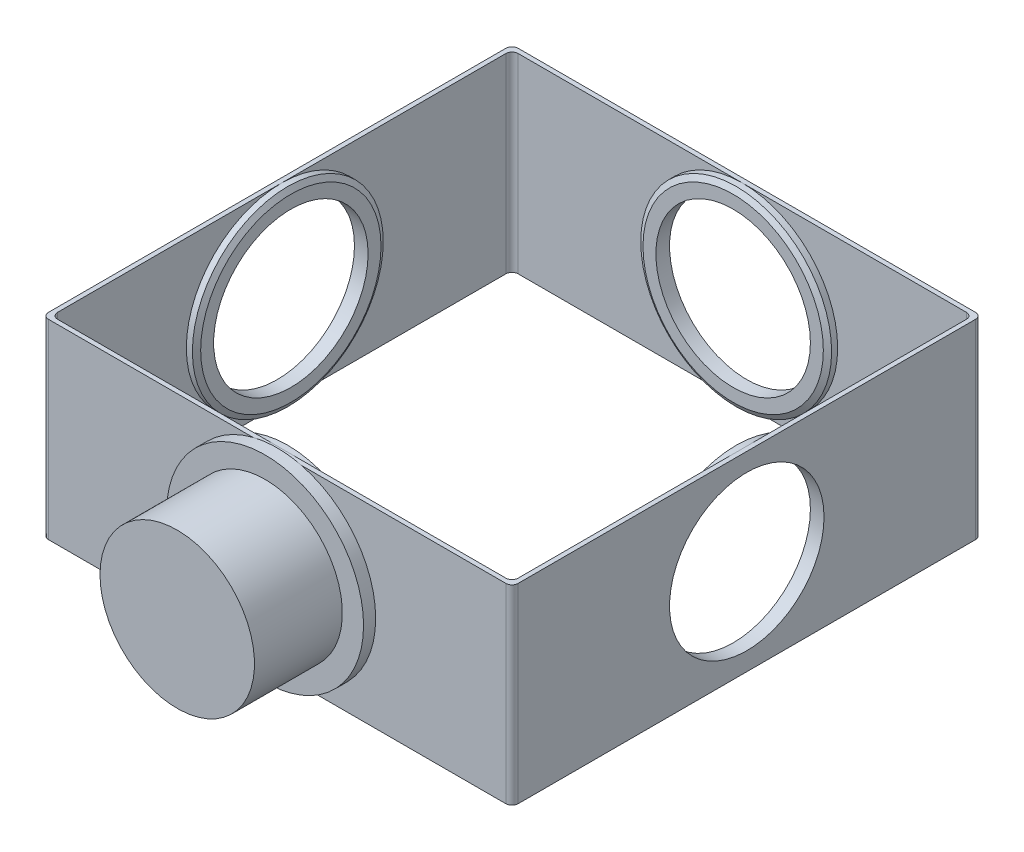
from build123d import *
from OCP.BRepFilletAPI import BRepFilletAPI_MakeChamfer

# Parameters (mm, degrees)
EXTRUDE_1_DEPTH     = 63
CUT_EXTRUDE_1_REACH = 230.077
SKETCH_2_R          = 25.5
CUT_EXTRUDE_2_REACH = 230.077
SKETCH_3_R          = 25.5
SKETCH_4_R          = 31.5
SKETCH_4_R_2        = 25.5
EXTRUDE_1_2_DEPTH   = 3
CHAMFER_1_SIZE      = 1
CHAMFER_1_SIZE2     = 1.732050808
SKETCH_5_R          = 31.5
SKETCH_5_R_2        = 25.5
EXTRUDE_4_DEPTH     = 3
CHAMFER_2_SIZE      = 1
CHAMFER_2_SIZE2     = 1.732050808
SKETCH_7_R          = 31.5
SKETCH_7_R_2        = 25.5
EXTRUDE_5_DEPTH     = 3
SKETCH_8_R          = 31.5
SKETCH_8_R_2        = 25.5
EXTRUDE_6_DEPTH     = 3
CHAMFER_3_SIZE      = 1
CHAMFER_3_SIZE2     = 1.732050808
SKETCH_9_R          = 32.5
EXTRUDE_7_DEPTH     = 4
SKETCH_10_R         = 25.5
EXTRUDE_8_DEPTH     = 29


with BuildPart() as part:
    # Эскиз1 → Extrude 1 (new body)
    with BuildSketch(Plane(origin=(0, 0, 0), x_dir=(1, 0, 0), z_dir=(0, 1, 0))):
        with BuildLine():
            Line((2, 0), (153, 0))
            ThreePointArc((153, 0), (154.414213562, 0.585786438), (155, 2))
            Line((155, 2), (155, 153))
            ThreePointArc((155, 153), (154.414213562, 154.414213562), (153, 155))
            Line((153, 155), (2, 155))
            ThreePointArc((2, 155), (0.585786438, 154.414213562), (0, 153))
            Line((0, 153), (0, 2))
            ThreePointArc((0, 2), (0.585786438, 0.585786438), (2, 0))
        make_face()
        with BuildLine():
            Line((3.5, 153.5), (151.5, 153.5))
            ThreePointArc((151.5, 153.5), (152.914213562, 152.914213562), (153.5, 151.5))
            Line((153.5, 151.5), (153.5, 3.5))
            ThreePointArc((153.5, 3.5), (152.914213562, 2.085786438), (151.5, 1.5))
            Line((151.5, 1.5), (3.5, 1.5))
            ThreePointArc((3.5, 1.5), (2.085786438, 2.085786438), (1.5, 3.5))
            Line((1.5, 3.5), (1.5, 151.5))
            ThreePointArc((1.5, 151.5), (2.085786438, 152.914213562), (3.5, 153.5))
        make_face(mode=Mode.SUBTRACT)
    extrude(amount=EXTRUDE_1_DEPTH)

    # Вырез-Вытянуть1: up to this face of the body (flat: up to its plane)
    cut_extrude_1_end = Plane(part.part.faces().sort_by_distance((77.5, 31.5, -155))[0])
    # Эскиз2 → Вырез-Вытянуть1 (cut, up to the picked face)
    with BuildSketch(Plane.XY, mode=Mode.PRIVATE) as cut_extrude_1_sk1:
        with Locations((77.5, 31.5)):
            Circle(SKETCH_2_R)
    cut_extrude_1_tool1 = split(extrude(cut_extrude_1_sk1.sketch, amount=-CUT_EXTRUDE_1_REACH, mode=Mode.PRIVATE), bisect_by=cut_extrude_1_end, keep=Keep.BOTH, mode=Mode.PRIVATE)
    add(cut_extrude_1_tool1.solids().sort_by(Axis((77.5, 31.5, 0), (0, 0, -1)))[0], mode=Mode.SUBTRACT)

    # Вырез-Вытянуть2: up to this face of the body (flat: up to its plane)
    cut_extrude_2_end = Plane(part.part.faces().sort_by_distance((0, 31.5, -77.5))[0])
    # Эскиз3 → Вырез-Вытянуть2 (cut, up to the picked face)
    with BuildSketch(Plane(origin=(155, 0, 0), x_dir=(0, 0, -1), z_dir=(1, 0, 0)), mode=Mode.PRIVATE) as cut_extrude_2_sk1:
        with Locations((77.5, 31.5)):
            Circle(SKETCH_3_R)
    cut_extrude_2_tool1 = split(extrude(cut_extrude_2_sk1.sketch, amount=-CUT_EXTRUDE_2_REACH, mode=Mode.PRIVATE), bisect_by=cut_extrude_2_end, keep=Keep.BOTH, mode=Mode.PRIVATE)
    add(cut_extrude_2_tool1.solids().sort_by(Axis((155, 31.5, -77.5), (-1, 0, 0)))[0], mode=Mode.SUBTRACT)

    # Эскиз4 → Extrude 1 2 (add)
    with BuildSketch(Plane(origin=(0, 0, -1.5), x_dir=(-1, 0, 0), z_dir=(0, 0, -1))):
        with Locations(Location((-77.5, 31.5, 0), (0, 0, 270))):
            Circle(SKETCH_4_R)
        with Locations(Location((-77.5, 31.5, 0), (0, 0, 180))):
            Circle(SKETCH_4_R_2, mode=Mode.SUBTRACT)
    extrude(amount=EXTRUDE_1_2_DEPTH)

    # Фаска1 шайба
    chamfer_1_edges = [part.edges().sort_by_distance(p)[0] for p in [
        (77.5, 63, -4.5),
    ]]
    chamfer_1_side = [part.faces().sort_by_distance(p)[0] for p in [
        (77.5, 63, -3),
    ]]
    chamfer(chamfer_1_edges, length=CHAMFER_1_SIZE, length2=CHAMFER_1_SIZE2, reference=chamfer_1_side[0])

    # Эскиз5 → Бобышка-Вытянуть4 (add)
    with BuildSketch(Plane(origin=(1.5, 0, 0), x_dir=(0, 0, -1), z_dir=(1, 0, 0))):
        with Locations(Location((77.5, 31.5, 0), (0, 0, 270))):
            Circle(SKETCH_5_R)
        with Locations((77.5, 31.5)):
            Circle(SKETCH_5_R_2, mode=Mode.SUBTRACT)
    extrude(amount=EXTRUDE_4_DEPTH)

    # Фаска2
    chamfer_2_edges = [part.edges().sort_by_distance(p)[0] for p in [
        (4.5, 63, -77.5),
    ]]
    chamfer_2_side = [part.faces().sort_by_distance(p)[0] for p in [
        (3, 63, -77.5),
    ]]
    chamfer(chamfer_2_edges, length=CHAMFER_2_SIZE, length2=CHAMFER_2_SIZE2, reference=chamfer_2_side[0])

    # Эскиз7 → Бобышка-Вытянуть5 (add)
    with BuildSketch(Plane.XY.offset(-153.5)):
        with Locations(Location((77.5, 31.5, 0), (0, 0, 270))):
            Circle(SKETCH_7_R)
        with Locations((77.5, 31.5)):
            Circle(SKETCH_7_R_2, mode=Mode.SUBTRACT)
    extrude(amount=EXTRUDE_5_DEPTH)

    # Эскиз8 → Бобышка-Вытянуть6 (add)
    with BuildSketch(Plane.ZY.offset(-153.5)):
        with Locations(Location((-77.5, 31.5, 0), (0, 0, 270))):
            Circle(SKETCH_8_R)
        with Locations(Location((-77.5, 31.5, 0), (0, 0, 180))):
            Circle(SKETCH_8_R_2, mode=Mode.SUBTRACT)
    extrude(amount=EXTRUDE_6_DEPTH)

    # Фаска3: one chamfer whose edges measure the first distance from different faces: ONE call of the kernel's chamfer builder (chamfer() names one face for all edges)
    chamfer_3_edges_1 = [part.edges().sort_by_distance(p)[0] for p in [
        (150.5, 63, -77.5),
    ]]
    chamfer_3_side_1 = [part.faces().sort_by_distance(p)[0] for p in [
        (152, 63, -77.5),
    ]]
    chamfer_3_edges_2 = [part.edges().sort_by_distance(p)[0] for p in [
        (77.5, 63, -150.5),
    ]]
    chamfer_3_side_2 = [part.faces().sort_by_distance(p)[0] for p in [
        (77.5, 63, -152),
    ]]
    chamfer_3 = BRepFilletAPI_MakeChamfer(part.part.solid().wrapped)
    for e in chamfer_3_edges_1:
        chamfer_3.Add(CHAMFER_3_SIZE, CHAMFER_3_SIZE2, e.wrapped, chamfer_3_side_1[0].wrapped)  # the first distance lies on this face
    for e in chamfer_3_edges_2:
        chamfer_3.Add(CHAMFER_3_SIZE, CHAMFER_3_SIZE2, e.wrapped, chamfer_3_side_2[0].wrapped)  # the first distance lies on this face
    add(Compound.cast(chamfer_3.Shape()), mode=Mode.REPLACE)

    # Эскиз9 → Бобышка-Вытянуть7 (add)
    with BuildSketch(Plane.XY):
        with Locations(Location((77.5, 31.5, 0), (0, 0, 104.250032698))):
            Circle(SKETCH_9_R)
    extrude(amount=EXTRUDE_7_DEPTH)

    # Эскиз10 → Бобышка-Вытянуть8 (add)
    with BuildSketch(Plane.XY.offset(4)):
        with Locations((77.5, 31.5)):
            Circle(SKETCH_10_R)
    extrude(amount=EXTRUDE_8_DEPTH)


solid = part.part
